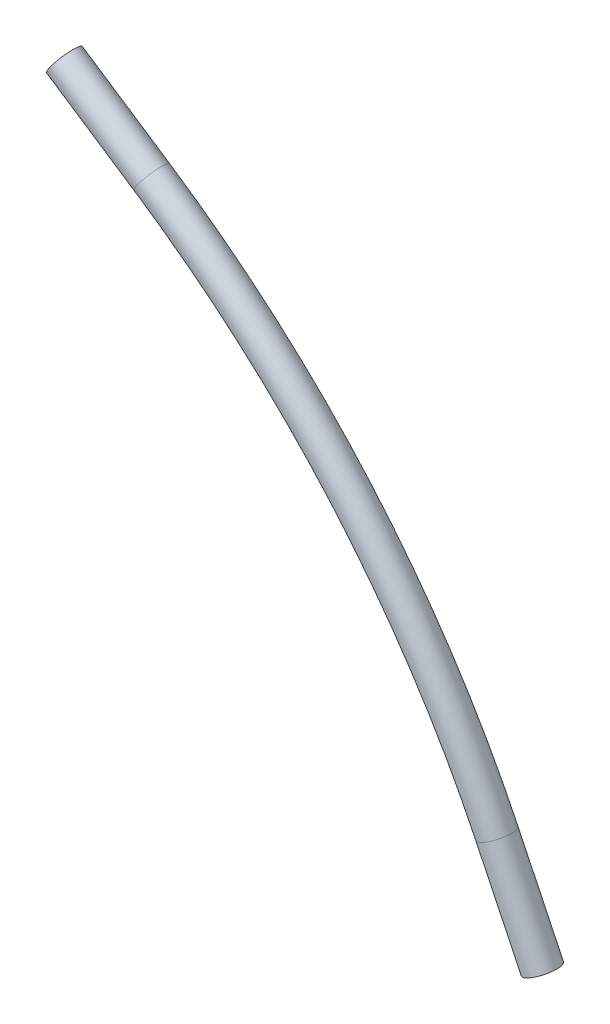
from build123d import *

# Parameters (mm, degrees)
VARREDURA1_PROFILE_R = 3


with BuildPart() as part:
    # Varredura1: sweep along a path in Esboço1
    with BuildLine(Plane.XY) as varredura1_path:
        Line((-45.410364748, 245.805534333), (-28.742484229, 234.751948534))
        ThreePointArc((-28.742484229, 234.751948534), (9.196246406, 201.491993129), (36.95625427, 159.361791619))
        Line((36.95625427, 159.361791619), (45.626935647, 141.339048086))
    # Varredura1 profile (on start of the path) → Varredura1 (sweep)
    with BuildSketch(Plane(origin=(-45.410364748, 245.805534333, 0), x_dir=(0.55267929, 0.833394026, 0), z_dir=(0.833394026, -0.55267929, 0))):
        Circle(VARREDURA1_PROFILE_R)
    sweep(path=varredura1_path.line)


solid = part.part
